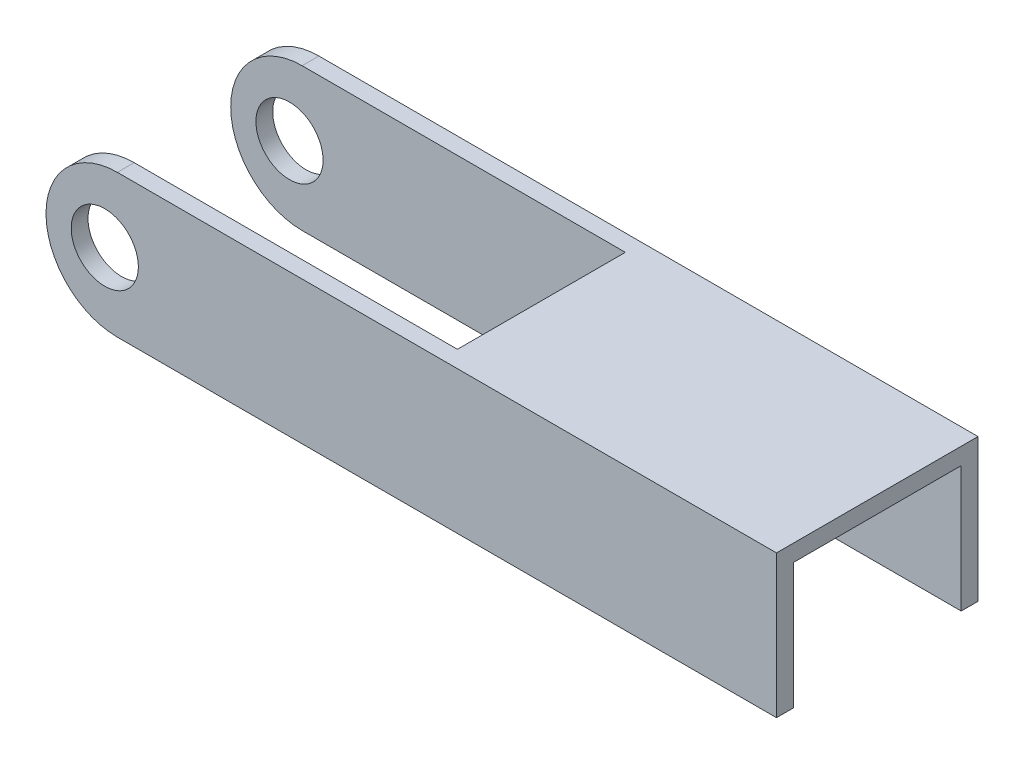
from build123d import *

# Parameters (mm, degrees)
SKETCH_1_R      = 4
EXTRUDE_1_DEPTH = 2
SKETCH_2_W      = 40
SKETCH_2_H      = 2
EXTRUDE_2_DEPTH = 20


with BuildPart() as part:
    # 草图1 → 凸台-拉伸1 (new body)
    with BuildSketch(Plane.XY):
        with BuildLine():
            Line((-4.303483184, 8.671520648), (4.196516816, 8.671520648))
            Line((4.196516816, 8.671520648), (74.196516816, 8.671520648))
            Line((74.196516816, 8.671520648), (74.196516816, -8.328479352))
            Line((74.196516816, -8.328479352), (-4.303483184, -8.328479352))
            ThreePointArc((-4.303483184, -8.328479352), (-12.803483184, 0.171520648), (-4.303483184, 8.671520648))
        make_face()
        with Locations((-5.803483184, 0.171520648)):
            Circle(SKETCH_1_R, mode=Mode.SUBTRACT)
    extrude_1 = extrude(amount=EXTRUDE_1_DEPTH)

    # 草图2 → 凸台-拉伸2 (add)
    with BuildSketch(Plane(origin=(0, 0, 0), x_dir=(-1, 0, 0), z_dir=(0, 0, -1))):
        with Locations((-54.196516816, 7.671520648)):
            Rectangle(SKETCH_2_W, SKETCH_2_H)
    extrude(amount=EXTRUDE_2_DEPTH)

    # 镜向1: 凸台-拉伸1 across plane
    add(extrude_1.mirror(Plane(origin=(0, 0, -10), x_dir=(1, 0, 0), z_dir=(0, 0, -1))))


solid = part.part
